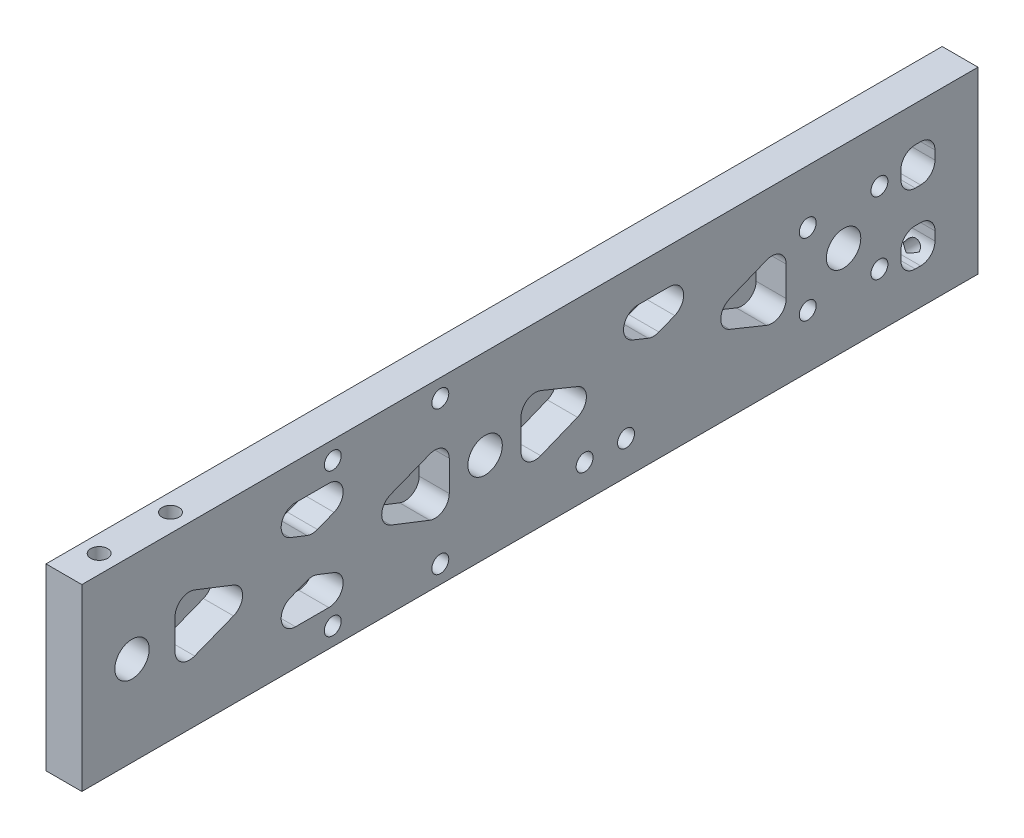
from build123d import *

# Parameters (mm, degrees)
SKETCH1_W                   = 6.35
SKETCH1_H                   = 158.75
BOSS_EXTRUDE1_DEPTH         = 31.75
SKETCH2_R                   = 3.048
AXLE_HOLES_DEPTH            = 7.35
F_3_0MM_DOWEL_HOLE2_D       = 3
SKETCH4_W                   = 6.0325
SKETCH4_H                   = 6.638636364
CHEESING_CUT_DEPTH          = 5.334
FILLET1_R                   = 2.54
F_3_0MM_DOWEL_HOLE1_D       = 3
M3X0_5_TAPPED_HOLE3_D       = 3
M3X0_5_TAPPED_HOLE3_DEPTH   = 14.9999954
M3X0_5_TAPPED_HOLE3_TIP     = 0.901290929
HOLE_WIZARD_7903_AT_2_COUNT = 2
HOLE_WIZARD_7903_AT_2_PITCH = 12.636677574
F_3_0MM_DOWEL_HOLE4_D       = 3
CIRPATTERN1_COUNT           = 4


with BuildPart() as part:
    # Sketch1 → Boss-Extrude1 (new body)
    with BuildSketch(Plane(origin=(0, 0, 0), x_dir=(1, 0, 0), z_dir=(0, 1, 0))):
        with Locations((-3.175, -79.375)):
            Rectangle(SKETCH1_W, SKETCH1_H)
    extrude(amount=BOSS_EXTRUDE1_DEPTH)

    # Sketch2 → axle holes (cut, through all)
    with BuildSketch(Plane(origin=(0, 0, 0), x_dir=(0, 0, -1), z_dir=(1, 0, 0))):
        with Locations((-23.8125, 15.875)):
            Circle(SKETCH2_R)
        with Locations((-87.3125, 15.875)):
            Circle(SKETCH2_R)
        with Locations((-149.86, 15.875)):
            Circle(SKETCH2_R)
    extrude(amount=-AXLE_HOLES_DEPTH, mode=Mode.SUBTRACT)

    # Ø3.0mm Dowel Hole2 (through all)
    with Locations(Plane(origin=(0, 0, 0), x_dir=(0, 0, -1), z_dir=(1, 0, 0))):
        with Locations((-114.3, 3.175), (-95.25, 3.175)):
            f_3_0mm_dowel_hole2 = Hole(F_3_0MM_DOWEL_HOLE2_D / 2)

    # Sketch4 → cheesing cut (cut)
    with BuildSketch(Plane(origin=(0, 0, 0), x_dir=(0, 0, -1), z_dir=(1, 0, 0))):
        Polygon((-125.857199693, 15.875), (-142.24, 22.299627571), (-142.24, 9.450372429), align=None)
        Polygon((-101.568449693, 25.4), (-134.334050307, 25.4), (-117.95125, 18.975372429), align=None)
        Polygon((-93.6625, 22.299627571), (-110.045300307, 15.875), (-93.6625, 9.450372429), align=None)
        Polygon((-101.568449693, 6.35), (-117.95125, 12.774627571), (-134.334050307, 6.35), align=None)
        Polygon((-65.150024324, 15.875), (-80.9625, 22.285463112), (-80.9625, 9.464536888), align=None)
        Polygon((-41.655024324, 25.4), (-73.279975676, 25.4), (-57.4675, 18.989536888), align=None)
        Polygon((-33.9725, 22.285463112), (-49.784975676, 15.875), (-33.9725, 9.464536888), align=None)
        with Locations((-10.63625, 9.669318182)):
            Rectangle(SKETCH4_W, SKETCH4_H)
        with Locations((-10.63625, 22.080681818)):
            Rectangle(SKETCH4_W, SKETCH4_H)
    extrude(amount=-CHEESING_CUT_DEPTH, mode=Mode.SUBTRACT)

    # Fillet1
    fillet1_edges = [part.edges().sort_by_distance(p)[0] for p in [
        (-2.667, 22.285463112, 80.9625),
        (-2.667, 15.875, 65.150024324),
        (-2.667, 9.464536888, 80.9625),
        (-2.667, 12.774627571, 117.95125),
        (-2.667, 6.35, 101.568449693),
        (-2.667, 6.35, 134.334050307),
        (-2.667, 25.4, 134.334050307),
        (-2.667, 25.4, 101.568449693),
        (-2.667, 18.975372429, 117.95125),
        (-2.667, 22.299627571, 93.6625),
        (-2.667, 9.450372429, 93.6625),
        (-2.667, 15.875, 110.045300307),
        (-2.667, 15.875, 49.784975676),
        (-2.667, 22.285463112, 33.9725),
        (-2.667, 9.464536888, 33.9725),
        (-2.667, 25.4, 73.279975676),
        (-2.667, 25.4, 41.655024324),
        (-2.667, 18.989536888, 57.4675),
        (-2.667, 12.988636364, 13.6525),
        (-2.667, 12.988636364, 7.62),
        (-2.667, 6.35, 7.62),
        (-2.667, 6.35, 13.6525),
        (-2.667, 18.761363636, 13.6525),
        (-2.667, 25.4, 13.6525),
        (-2.667, 25.4, 7.62),
        (-2.667, 18.761363636, 7.62),
        (-2.667, 15.875, 125.857199693),
        (-2.667, 9.450372429, 142.24),
        (-2.667, 22.299627571, 142.24),
    ]]
    fillet(fillet1_edges, radius=FILLET1_R)

    # Mirror1: Ø3.0mm Dowel Hole2 across plane
    add(f_3_0mm_dowel_hole2.mirror(Plane.ZX.offset(15.875)), mode=Mode.SUBTRACT)

    # Ø3.0mm Dowel Hole1 (through all)
    with Locations(Plane(origin=(0, 0, 0), x_dir=(0, 0, -1), z_dir=(1, 0, 0))):
        with Locations((-69.685396292, 6), (-62.351396292, 6)):
            Hole(F_3_0MM_DOWEL_HOLE1_D / 2)

    # M3x0.5 Tapped Hole3
    with Locations(Plane(origin=(101.342838782, 5.251462055, -6.35), x_dir=(-1, 0, 0), z_dir=(0, 0, -1))):
        with Locations((104.517838782, 20.148537945), (104.517838782, 1.098537945)):
            Hole(M3X0_5_TAPPED_HOLE3_D / 2, depth=M3X0_5_TAPPED_HOLE3_DEPTH)
            with Locations((0, 0, -(M3X0_5_TAPPED_HOLE3_DEPTH + M3X0_5_TAPPED_HOLE3_TIP / 2))):  # 118° drill point
                Cone(0, M3X0_5_TAPPED_HOLE3_D / 2, M3X0_5_TAPPED_HOLE3_TIP, mode=Mode.SUBTRACT)

    # Sketch18 → Hole Wizard 7903 (revolve, cut)
    with BuildSketch(Plane(origin=(-3.236678341, -2.577911324, 139.812714896), x_dir=(0, -0.001998321, -0.999998003), z_dir=(1, 0, 0))):
        Polygon((0, 0), (0, 8.521290929), (1.5, 7.62), (1.5, 0), align=None)
    hole_wizard_7903 = revolve(axis=Axis((-3.236678341, -8.927898646, 139.825404238), (0, 0.999998003, -0.001998321)), mode=Mode.SUBTRACT)

    # Hole Wizard 7903 at 2: Hole Wizard 7903 ×2
    with Locations(*[Vector(0, 0.001998321, 0.999998003) * (i * HOLE_WIZARD_7903_AT_2_PITCH) for i in range(1, HOLE_WIZARD_7903_AT_2_COUNT)]):
        add(hole_wizard_7903, mode=Mode.SUBTRACT)

    # Mirror2: Hole Wizard 7903 across plane
    add(hole_wizard_7903.mirror(Plane.ZX.offset(15.875)), mode=Mode.SUBTRACT)

    # Mirror2 copy 1 sketch → Mirror2 copy 1 (revolve, cut)
    with BuildSketch(Plane(origin=(-3.236678341, 34.30265918, 152.449367239), x_dir=(0, 0.001998321, -0.999998003), z_dir=(1, 0, 0))):
        Polygon((0, 0), (0, -8.521290929), (1.5, -7.62), (1.5, 0), align=None)
    revolve(axis=Axis((-3.236678341, 40.652646501, 152.462056581), (0, 0.999998003, 0.001998321)), mode=Mode.SUBTRACT)

    # Ø3.0mm Dowel Hole4 (through all)
    with Locations(Plane(origin=(0, 0, 0), x_dir=(0, 0, -1), z_dir=(1, 0, 0))):
        with Locations((-30.1625, 22.225)):
            f_3_0mm_dowel_hole4 = Hole(F_3_0MM_DOWEL_HOLE4_D / 2)

    # CirPattern1: Ø3.0mm Dowel Hole4 ×4 about axis
    cirpattern1_axis = Axis((0, 15.875, 23.8125), (1, 0, 0))
    for i in range(1, CIRPATTERN1_COUNT):
        add(f_3_0mm_dowel_hole4.rotate(cirpattern1_axis, i * 360 / CIRPATTERN1_COUNT), mode=Mode.SUBTRACT)


solid = part.part
